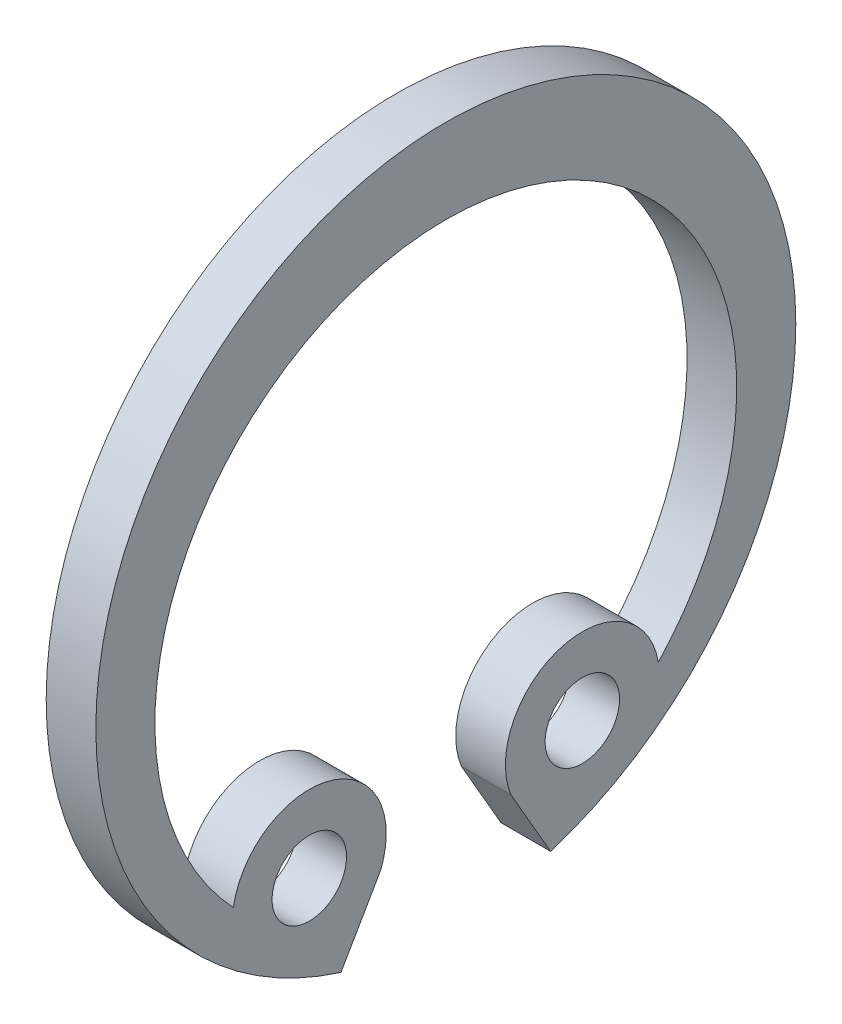
from build123d import *

# Parameters (mm, degrees)
BOSS_EXTRUDE1_DEPTH      = 0.5
BOSS_EXTRUDE1_DEPTH_BACK = 0.5
SKETCH1_R                = 0.75


with BuildPart() as part:
    # Sketch1 → Boss-Extrude1 (new, two sides: drawn at the far end of the back side and taken through both)
    with BuildSketch(Plane(origin=(0, 0, 0), x_dir=(0, 0, -1), z_dir=(1, 0, 0)).offset(-BOSS_EXTRUDE1_DEPTH_BACK)):
        with BuildLine():
            Line((-2.111537106, -6.72635942), (-1.311849217, -5.341259368))
            ThreePointArc((-1.311849217, -5.341259368), (-2.333344184, -3.270190314), (-4.279681349, -4.512989826))
            ThreePointArc((-4.279681349, -4.512989826), (0, 5.35), (4.279681349, -4.512989826))
            ThreePointArc((4.279681349, -4.512989826), (2.333344184, -3.270190314), (1.311849217, -5.341259368))
            Line((1.311849217, -5.341259368), (2.111537106, -6.72635942))
            ThreePointArc((2.111537106, -6.72635942), (0, 7.05), (-2.111537106, -6.72635942))
        make_face()
        with Locations((2.75, -4.763139721)):
            Circle(SKETCH1_R, mode=Mode.SUBTRACT)
        with Locations((-2.75, -4.763139721)):
            Circle(SKETCH1_R, mode=Mode.SUBTRACT)
    extrude(amount=BOSS_EXTRUDE1_DEPTH + BOSS_EXTRUDE1_DEPTH_BACK)


solid = part.part
